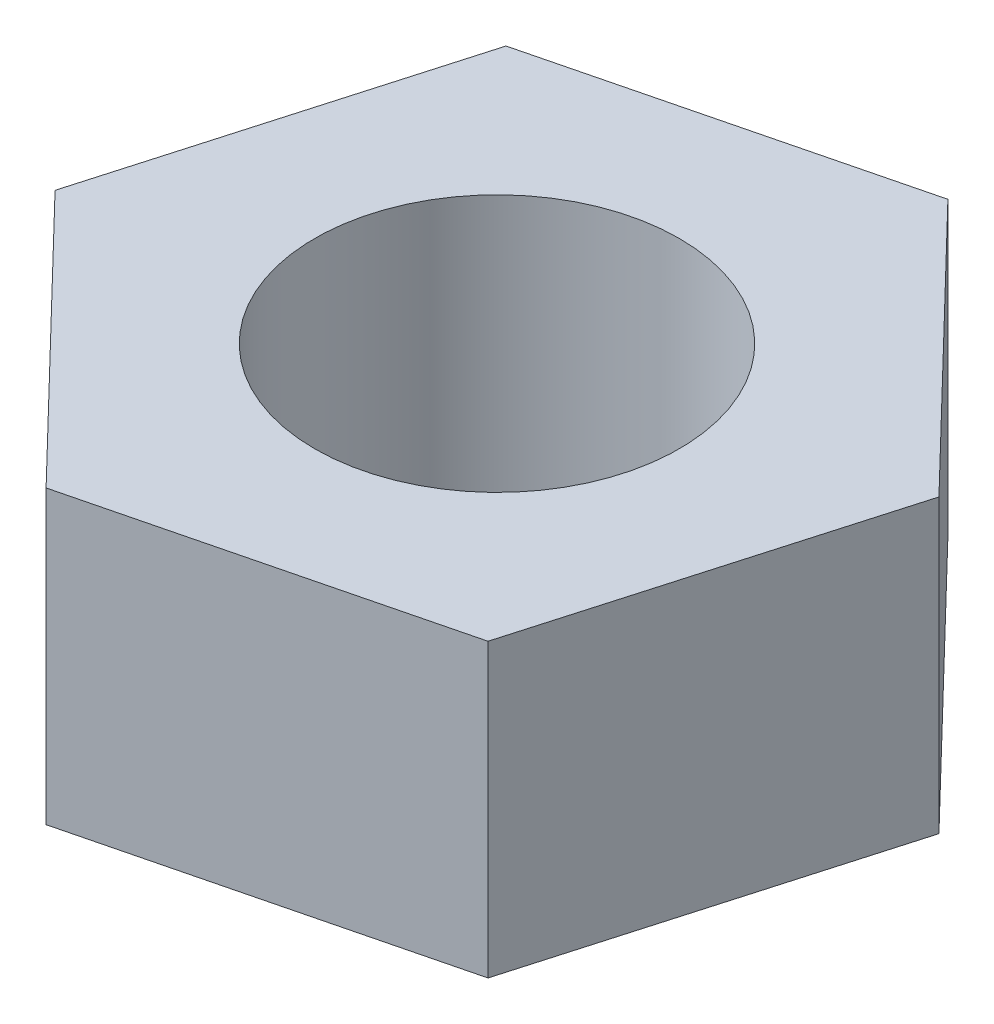
from build123d import *

# Parameters (mm, degrees)
SKETCH1_R           = 3.175
BOSS_EXTRUDE2_DEPTH = 5.08


with BuildPart() as part:
    # Sketch1 → Boss-Extrude2 (new body)
    with BuildSketch(Plane(origin=(0, 0, 0), x_dir=(1, 0, 0), z_dir=(0, 1, 0))):
        Polygon((6.161310808, 1.53647295), (1.750030797, 6.104088155), (-4.411280011, 4.567615205), (-6.161310808, -1.53647295), (-1.750030797, -6.104088155), (4.411280011, -4.567615205), align=None)
        Circle(SKETCH1_R, mode=Mode.SUBTRACT)
    extrude(amount=BOSS_EXTRUDE2_DEPTH)


solid = part.part
